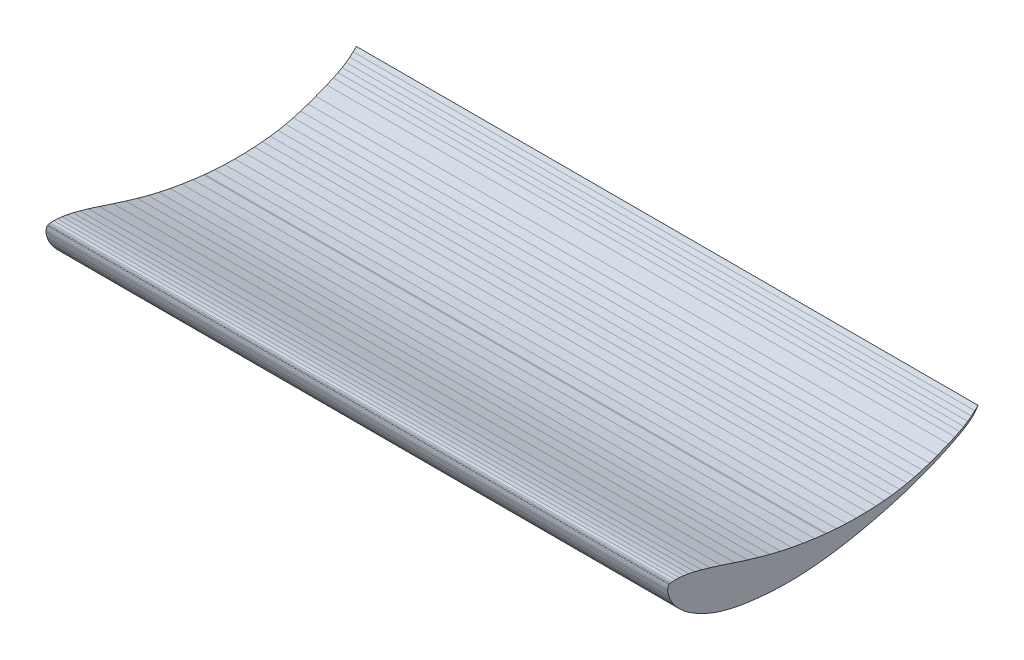
from build123d import *

# Parameters (mm, degrees)
BOSS_EXTRUDE3_DEPTH = 1000


with BuildPart() as part:
    # Sketch1 → Boss-Extrude3 (new body)
    with BuildSketch(Plane(origin=(0, 0, -500), x_dir=(0, 0, -1), z_dir=(1, 0, 0))):
        Polygon((-642.779409885, 256.120502949), (-644.914388657, 255.904585123), (-646.200299263, 255.71128726), (-646.685421467, 255.589991808), (-647.101521492, 255.439013243), (-647.425472736, 255.27459383), (-647.714614868, 255.077391863), (-647.978484631, 254.839211702), (-648.275375366, 254.489988089), (-648.636221886, 253.934204578), (-649.123728275, 252.929896116), (-649.30999279, 252.462893724), (-649.766325951, 250.954300165), (-650.021493435, 249.423295259), (-650.094270706, 247.779801488), (-650.038719177, 246.605500579), (-649.602711201, 243.699401617), (-648.441672325, 239.474505186), (-647.353470325, 236.322000623), (-645.422577858, 231.728598475), (-643.051326275, 227.357104421), (-640.120506287, 222.93870151), (-636.568427086, 218.405202031), (-632.264912128, 213.678896427), (-627.326071262, 208.981901407), (-621.761500835, 204.359397292), (-615.521609783, 199.795395136), (-608.5485816, 195.271506906), (-600.728929043, 190.76859951), (-596.005380154, 188.305199146), (-587.184429169, 184.160396457), (-577.917218208, 180.371597409), (-568.137705326, 176.927000284), (-557.888925076, 173.8602072), (-547.180473804, 171.18909955), (-536.01872921, 168.915003538), (-534.444212914, 168.630793691), (-521.650195122, 166.604802012), (-508.135974407, 164.908796549), (-492.430597544, 163.390293717), (-475.852102041, 162.333399057), (-459.896713495, 161.8847996), (-444.510787725, 162.004098296), (-429.100692272, 162.644594908), (-413.232386112, 163.816794753), (-396.332412958, 165.601596236), (-379.418700933, 167.905002832), (-361.880987883, 170.800805092), (-343.654692173, 174.315303564), (-324.638485909, 178.4837991), (-304.697185755, 183.361396194), (-286.849200726, 188.203394413), (-270.105808973, 193.222895265), (-252.515107393, 199.067205191), (-235.948398709, 205.165296793), (-219.85130012, 211.677998304), (-204.168900847, 218.616306782), (-191.308796406, 224.782302976), (-180.752694607, 230.286598206), (-173.555895686, 234.368100762), (-168.321296573, 237.659201026), (-163.910001516, 240.874201059), (-160.164996982, 244.140699506), (-156.561002135, 247.982501984), (-153.336599469, 252.174496651), (-150.913998485, 255.951285362), (-156.019702554, 250.904113054), (-161.501795053, 246.226206422), (-167.419299483, 241.865903139), (-173.723697662, 237.868800759), (-180.422201753, 234.187602997), (-187.979504466, 230.538204312), (-198.573499918, 226.002797484), (-216.145798564, 219.094693661), (-228.632703424, 214.508801699), (-240.639105439, 210.572898388), (-252.248704433, 207.256004214), (-264.682114124, 204.265296459), (-276.933789253, 201.882794499), (-289.279103279, 200.03400743), (-301.696509123, 198.68889451), (-314.927399158, 197.707295418), (-329.930603504, 197.033897042), (-346.439599991, 196.817696095), (-362.657696009, 197.159305215), (-378.566503525, 198.04109633), (-394.465506077, 199.431404471), (-396.365493536, 199.629202485), (-413.707196712, 201.723203063), (-431.453704834, 204.358592629), (-450.356990099, 207.704395056), (-468.465685844, 211.488306522), (-485.652685165, 215.641096234), (-502.897024155, 220.307901502), (-521.483182907, 225.811600685), (-541.911184788, 232.310399413), (-564.286708832, 239.661693573), (-582.044124603, 245.254397392), (-595.689117908, 249.179899693), (-606.637179852, 251.971691847), (-616.060674191, 253.978610039), (-624.257326126, 255.313187838), (-631.537616253, 256.076693535), (-637.538611889, 256.317704916), align=None)
    extrude(amount=BOSS_EXTRUDE3_DEPTH)


solid = part.part
